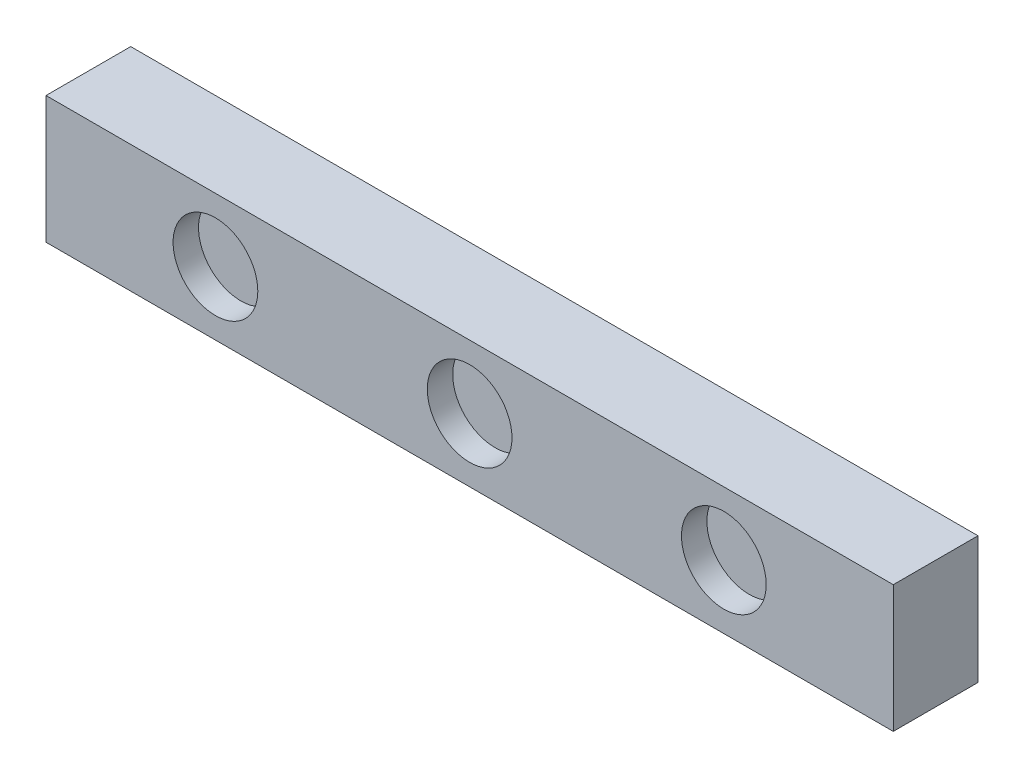
from build123d import *

# Parameters (mm, degrees)
SKETCH2_W           = 1000
SKETCH2_H           = 150
BOSS_EXTRUDE2_DEPTH = 100
SKETCH2_5_R         = 50
CUT_EXTRUDE1_DEPTH  = 30


with BuildPart() as part:
    # Sketch2 → Boss-Extrude2 (new body)
    with BuildSketch(Plane.XY):
        Rectangle(SKETCH2_W, SKETCH2_H)
    extrude(amount=-BOSS_EXTRUDE2_DEPTH)

    # Sketch2_5 → Cut-Extrude1 (cut)
    with BuildSketch(Plane.XY):
        Circle(SKETCH2_5_R)
        with Locations((300, 0)):
            Circle(SKETCH2_5_R)
        with Locations((-300, 0)):
            Circle(SKETCH2_5_R)
    extrude(amount=-CUT_EXTRUDE1_DEPTH, mode=Mode.SUBTRACT)


solid = part.part
